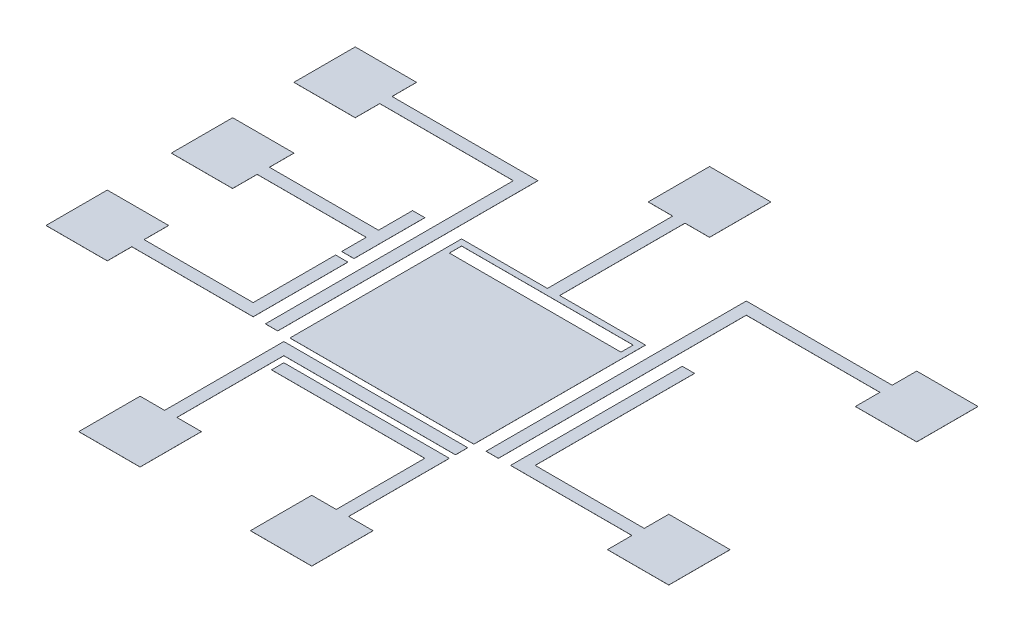
from build123d import *

# Parameters (mm, degrees)
SKETCH1_W           = 10
SKETCH1_H           = 10
SKETCH1_W_2         = 14
SKETCH1_H_2         = 1
BOSS_EXTRUDE1_DEPTH = 0.007


with BuildPart() as part:
    # Sketch1 → Boss-Extrude1 (new body)
    with BuildSketch(Plane(origin=(0, 0, 0), x_dir=(1, 0, 0), z_dir=(0, 1, 0))):
        Polygon((5, 18.225), (0, 18.225), (0, 13.225), (5, 13.225), (5, 15.225), (14.9, 15.225), (14.9, 22.948719865), (13.9, 22.948719865), (13.9, 16.225), (5, 16.225), align=None)
        Polygon((5, 28.448719865), (0, 28.448719865), (0, 23.448719865), (5, 23.448719865), (5, 25.448719865), (13.9, 25.448719865), (13.9, 23.448719865), (14.9, 23.448719865), (14.9, 29.225), (13.9, 29.225), (13.9, 26.448719865), (5, 26.448719865), align=None)
        Polygon((5, 38.448719865), (0, 38.448719865), (0, 33.448719865), (5, 33.448719865), (5, 35.448719865), (15.9, 35.448719865), (15.9, 15.225), (16.9, 15.225), (16.9, 36.448719865), (5, 36.448719865), align=None)
        Polygon((32.9, 29.225), (25.9, 29.225), (25.9, 39.45), (27.9, 39.45), (27.9, 44.45), (22.9, 44.45), (22.9, 39.45), (24.9, 39.45), (24.9, 29.225), (17.9, 29.225), (17.9, 15.225), (32.9, 15.225), align=None)
        with Locations((25.4, 22.225)):
            Rectangle(SKETCH1_W, SKETCH1_H, mode=Mode.SUBTRACT)
        with Locations((25.4, 28.225)):
            Rectangle(SKETCH1_W_2, SKETCH1_H_2, mode=Mode.SUBTRACT)
        Polygon((50.8, 33.448719865), (50.8, 38.448719865), (45.8, 38.448719865), (45.8, 36.448719865), (33.9, 36.448719865), (33.9, 15.225), (34.9, 15.225), (34.9, 35.448719865), (45.8, 35.448719865), (45.8, 33.448719865), align=None)
        Polygon((50.8, 13.225), (50.8, 18.225), (45.8, 18.225), (45.8, 16.225), (36.9, 16.225), (36.9, 29.225), (35.9, 29.225), (35.9, 15.225), (45.8, 15.225), (45.8, 13.225), align=None)
        Polygon((29.9, 0), (34.9, 0), (34.9, 5), (32.9, 5), (32.9, 13.225), (19.4, 13.225), (19.4, 12.225), (31.9, 12.225), (31.9, 5), (29.9, 5), align=None)
        Polygon((15.9, 0), (20.9, 0), (20.9, 5), (18.9, 5), (18.9, 13.725), (32.9, 13.725), (32.9, 14.725), (17.9, 14.725), (17.9, 5), (15.9, 5), align=None)
        with Locations((25.4, 22.225)):
            Rectangle(SKETCH1_W, SKETCH1_H)
    extrude(amount=BOSS_EXTRUDE1_DEPTH)


solid = part.part
